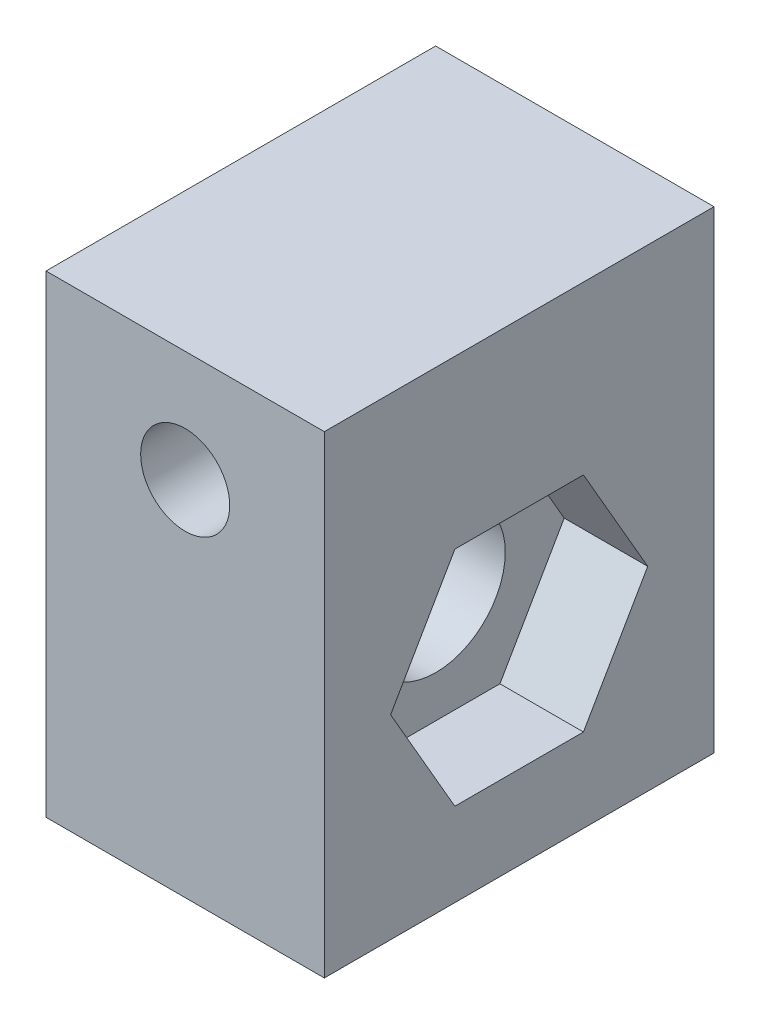
from build123d import *

# Parameters (mm, degrees)
SKETCH1_W           = 10
SKETCH1_H           = 17
BOSS_EXTRUDE1_DEPTH = 14
SKETCH2_R           = 1.6
CUT_EXTRUDE1_DEPTH  = 15
CUT_EXTRUDE2_DEPTH  = 3
SKETCH5_R           = 2.5
CUT_EXTRUDE3_DEPTH  = 8


with BuildPart() as part:
    # Sketch1 → Boss-Extrude1 (new body)
    with BuildSketch(Plane.XY):
        Rectangle(SKETCH1_W, SKETCH1_H)
    extrude(amount=BOSS_EXTRUDE1_DEPTH)

    # Sketch2 → Cut-Extrude1 (cut, through all)
    with BuildSketch(Plane(origin=(0, 0, 0), x_dir=(-1, 0, 0), z_dir=(0, 0, -1))):
        with Locations((0, 4.5)):
            Circle(SKETCH2_R)
    extrude(amount=-CUT_EXTRUDE1_DEPTH, mode=Mode.SUBTRACT)

    # Sketch3 → Cut-Extrude2 (cut)
    with BuildSketch(Plane.ZY.offset(5)):
        Polygon((2.381197846, -1.5), (4.690598923, -5.5), (9.309401077, -5.5), (11.618802154, -1.5), (9.309401077, 2.5), (4.690598923, 2.5), align=None)
    cut_extrude2 = extrude(amount=-CUT_EXTRUDE2_DEPTH, mode=Mode.SUBTRACT)

    # Sketch5 → Cut-Extrude3 (cut, through all)
    with BuildSketch(Plane.ZY.offset(2)):
        with Locations((7, -1.5)):
            Circle(SKETCH5_R)
    extrude(amount=-CUT_EXTRUDE3_DEPTH, mode=Mode.SUBTRACT)

    # Mirror1: Cut-Extrude2 across plane
    add(cut_extrude2.mirror(Plane(origin=(0, 0, 0), x_dir=(0, 0, 1), z_dir=(1, 0, 0))), mode=Mode.SUBTRACT)


solid = part.part
